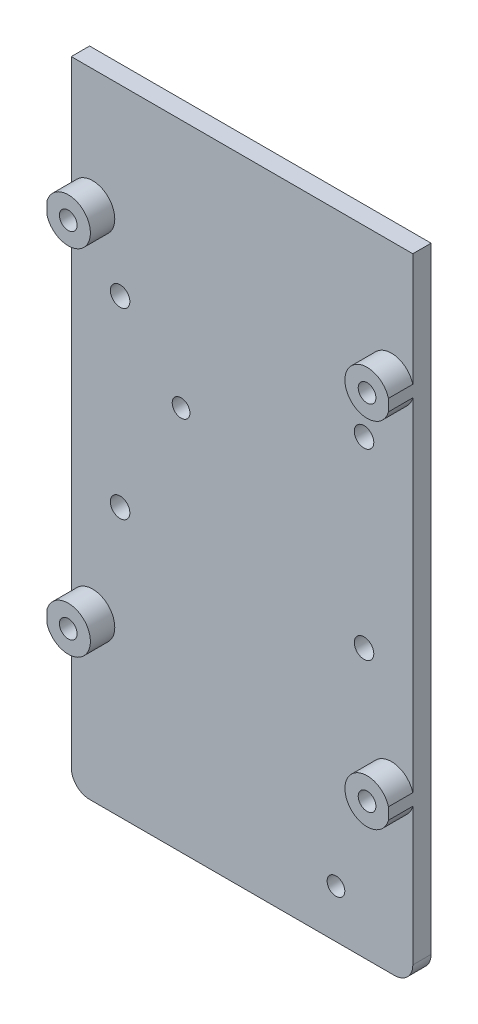
from build123d import *

# Parameters (mm, degrees)
BOSS_EXTRUDE1_DEPTH = 3
SKETCH3_R           = 1.6
SKETCH3_R_2         = 1.45
CUT_EXTRUDE1_DEPTH  = 4
SKETCH4_R           = 1.45
BOSS_EXTRUDE2_DEPTH = 4


with BuildPart() as part:
    # Sketch2 → Boss-Extrude1 (new body)
    with BuildSketch(Plane.XY):
        with BuildLine():
            Line((-55.566838563, -38.131712133), (-5.566838563, -38.131712133))
            ThreePointArc((-5.566838563, -38.131712133), (-3.44551822, -37.253032477), (-2.566838563, -35.131712133))
            Line((-2.566838563, -35.131712133), (-2.566838563, 65.868287867))
            Line((-2.566838563, 65.868287867), (-58.566838563, 65.868287867))
            Line((-58.566838563, 65.868287867), (-58.566838563, -35.131712133))
            ThreePointArc((-58.566838563, -35.131712133), (-57.688158907, -37.253032477), (-55.566838563, -38.131712133))
        make_face()
    extrude(amount=BOSS_EXTRUDE1_DEPTH)

    # Sketch3 → Cut-Extrude1 (cut, through all)
    with BuildSketch(Plane.XY.offset(3)):
        with Locations((-50.566838563, 35.868287867)):
            Circle(SKETCH3_R)
        with Locations((-50.566838563, 5.868287867)):
            Circle(SKETCH3_R)
        with Locations((-10.566838563, 5.868287867)):
            Circle(SKETCH3_R)
        with Locations((-10.566838563, 35.868287867)):
            Circle(SKETCH3_R)
        with Locations((-40.566838563, 24.968287867)):
            Circle(SKETCH3_R_2)
        with Locations((-15.166838563, -30.231712133)):
            Circle(SKETCH3_R_2)
        with Locations((-6.066838563, 46.368287867)):
            Circle(SKETCH3_R_2)
        with Locations((-6.066838563, -11.631712133)):
            Circle(SKETCH3_R_2)
        with Locations((-55.066838563, -11.631712133)):
            Circle(SKETCH3_R_2)
        with Locations((-55.066838563, 46.368287867)):
            Circle(SKETCH3_R_2)
    extrude(amount=-CUT_EXTRUDE1_DEPTH, mode=Mode.SUBTRACT)

    # Sketch4 → Boss-Extrude2 (add)
    with BuildSketch(Plane.XY.offset(3)):
        with BuildLine():
            Line((-58.566838563, -10.671563034), (-58.566838563, -12.591861232))
            ThreePointArc((-58.566838563, -12.591861232), (-54.582429852, -15.228548867), (-51.437529223, -11.631712133))
            ThreePointArc((-51.437529223, -11.631712133), (-54.582429852, -8.034875399), (-58.566838563, -10.671563034))
        make_face()
        with Locations((-55.066838563, -11.631712133)):
            Circle(SKETCH4_R, mode=Mode.SUBTRACT)
        with BuildLine():
            Line((-58.566838563, 47.328436966), (-58.566838563, 45.408138768))
            ThreePointArc((-58.566838563, 45.408138768), (-54.582429852, 42.771451133), (-51.437529223, 46.368287867))
            ThreePointArc((-51.437529223, 46.368287867), (-54.582429852, 49.965124601), (-58.566838563, 47.328436966))
        make_face()
        with Locations((-55.066838563, 46.368287867)):
            Circle(SKETCH4_R, mode=Mode.SUBTRACT)
        with BuildLine():
            ThreePointArc((-2.566838563, -10.671563034), (-9.696147904, -11.631712133), (-2.566838563, -12.591861232))
            Line((-2.566838563, -12.591861232), (-2.566838563, -10.671563034))
        make_face()
        with Locations((-6.066838563, -11.631712133)):
            Circle(SKETCH4_R, mode=Mode.SUBTRACT)
        with BuildLine():
            ThreePointArc((-2.566838563, 47.328436966), (-9.696147904, 46.368287867), (-2.566838563, 45.408138768))
            Line((-2.566838563, 45.408138768), (-2.566838563, 47.328436966))
        make_face()
        with Locations((-6.066838563, 46.368287867)):
            Circle(SKETCH4_R, mode=Mode.SUBTRACT)
    extrude(amount=BOSS_EXTRUDE2_DEPTH)


solid = part.part
